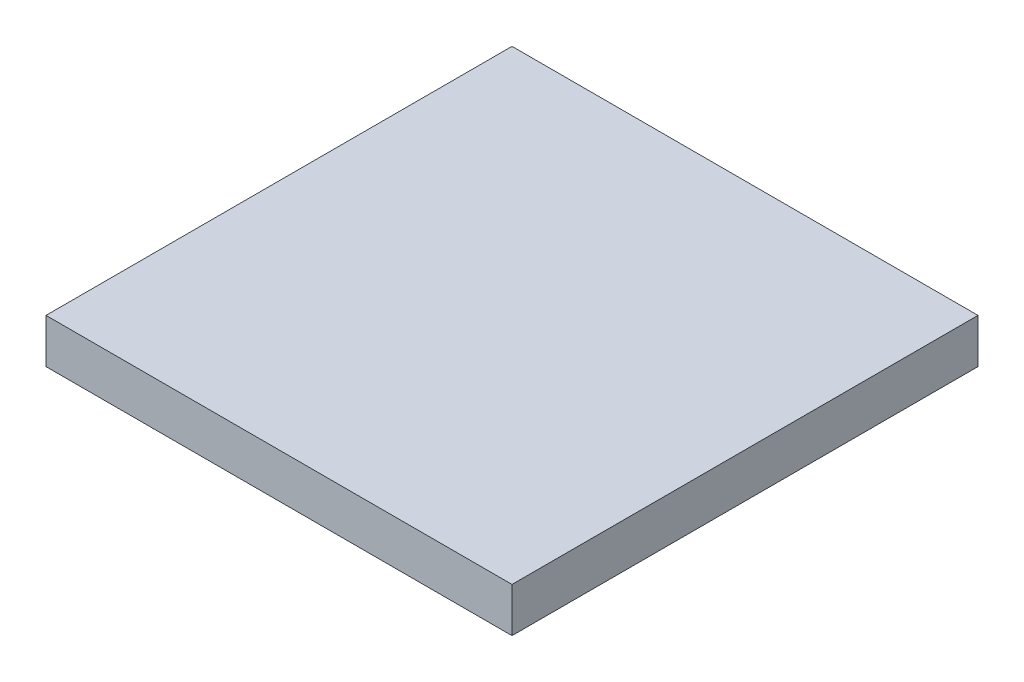
from build123d import *

# Parameters (mm, degrees)
SKETCH1_W           = 533.4
SKETCH1_H           = 533.4
BOSS_EXTRUDE1_DEPTH = 50.8


with BuildPart() as part:
    # Sketch1 → Boss-Extrude1 (new body)
    with BuildSketch(Plane(origin=(0, 0, 0), x_dir=(1, 0, 0), z_dir=(0, 1, 0))):
        Rectangle(SKETCH1_W, SKETCH1_H)
    extrude(amount=BOSS_EXTRUDE1_DEPTH)


solid = part.part
